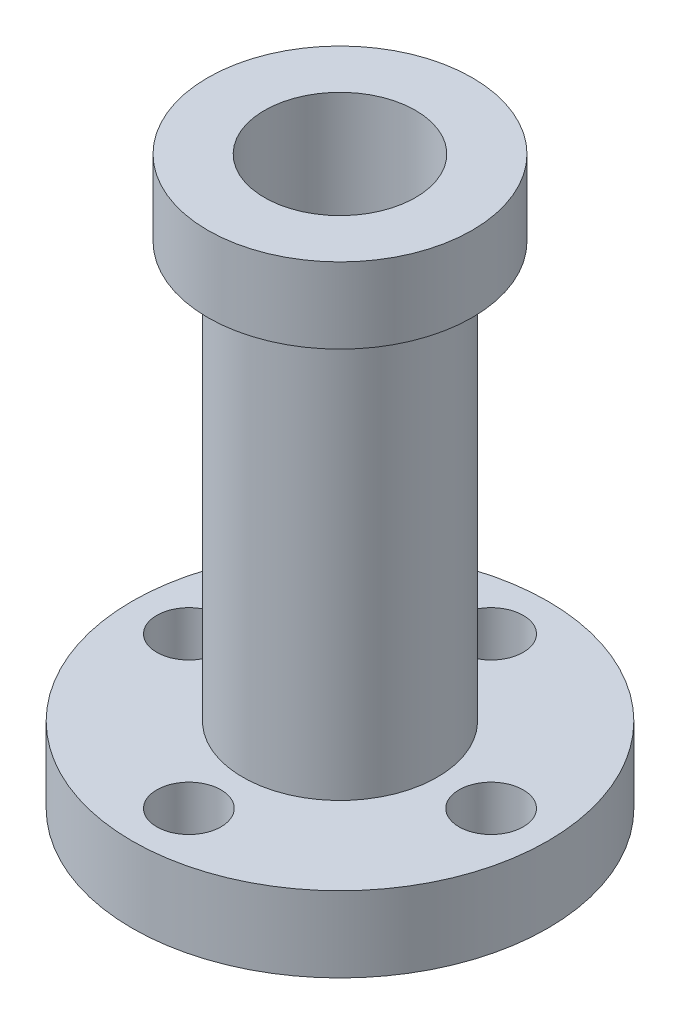
from build123d import *

# Parameters (mm, degrees)
M3_CLEARANCE_HOLE1_REACH  = 35.793
M3_CLEARANCE_HOLE1_BORE_R = 1.7


with BuildPart() as part:
    # Sketch2 → Revolve1 (revolve)
    with BuildSketch(Plane.XY, mode=Mode.PRIVATE) as revolve1_sk:
        Polygon((4, 30), (4, 0), (11, 0), (11, 4), (5.15, 4), (5.15, 26), (7, 26), (7, 30), align=None)
    revolve(revolve1_sk.sketch.rotate(Axis((0, 0, 0), (0, 1, 0)), 90), axis=Axis((0, 0, 0), (0, 1, 0)))

    # M3 Clearance Hole1 bore → M3 Clearance Hole1 (cut, up to next)
    with BuildSketch(Plane(origin=(0, 0, 0), x_dir=(-1, 0, 0), z_dir=(0, -1, 0)), mode=Mode.PRIVATE) as m3_clearance_hole1_sk1:
        with Locations((0, -8)):
            Circle(M3_CLEARANCE_HOLE1_BORE_R)
    m3_clearance_hole1_tool1 = extrude(m3_clearance_hole1_sk1.sketch, amount=-M3_CLEARANCE_HOLE1_REACH, mode=Mode.PRIVATE) & part.part
    # M3 Clearance Hole1 bore → M3 Clearance Hole1 (cut, up to next)
    with BuildSketch(Plane(origin=(0, 0, 0), x_dir=(-1, 0, 0), z_dir=(0, -1, 0)), mode=Mode.PRIVATE) as m3_clearance_hole1_sk2:
        with Locations((-8, 0)):
            Circle(M3_CLEARANCE_HOLE1_BORE_R)
    m3_clearance_hole1_tool2 = extrude(m3_clearance_hole1_sk2.sketch, amount=-M3_CLEARANCE_HOLE1_REACH, mode=Mode.PRIVATE) & part.part
    # M3 Clearance Hole1 bore → M3 Clearance Hole1 (cut, up to next)
    with BuildSketch(Plane(origin=(0, 0, 0), x_dir=(-1, 0, 0), z_dir=(0, -1, 0)), mode=Mode.PRIVATE) as m3_clearance_hole1_sk3:
        with Locations((0, 8)):
            Circle(M3_CLEARANCE_HOLE1_BORE_R)
    m3_clearance_hole1_tool3 = extrude(m3_clearance_hole1_sk3.sketch, amount=-M3_CLEARANCE_HOLE1_REACH, mode=Mode.PRIVATE) & part.part
    # M3 Clearance Hole1 bore → M3 Clearance Hole1 (cut, up to next)
    with BuildSketch(Plane(origin=(0, 0, 0), x_dir=(-1, 0, 0), z_dir=(0, -1, 0)), mode=Mode.PRIVATE) as m3_clearance_hole1_sk4:
        with Locations((8, 0)):
            Circle(M3_CLEARANCE_HOLE1_BORE_R)
    m3_clearance_hole1_tool4 = extrude(m3_clearance_hole1_sk4.sketch, amount=-M3_CLEARANCE_HOLE1_REACH, mode=Mode.PRIVATE) & part.part
    add(m3_clearance_hole1_tool1.solids().sort_by_distance((0, 0, 8))[0], mode=Mode.SUBTRACT)
    add(m3_clearance_hole1_tool2.solids().sort_by_distance((8, 0, 0))[0], mode=Mode.SUBTRACT)
    add(m3_clearance_hole1_tool3.solids().sort_by_distance((0, 0, -8))[0], mode=Mode.SUBTRACT)
    add(m3_clearance_hole1_tool4.solids().sort_by_distance((-8, 0, 0))[0], mode=Mode.SUBTRACT)


solid = part.part
